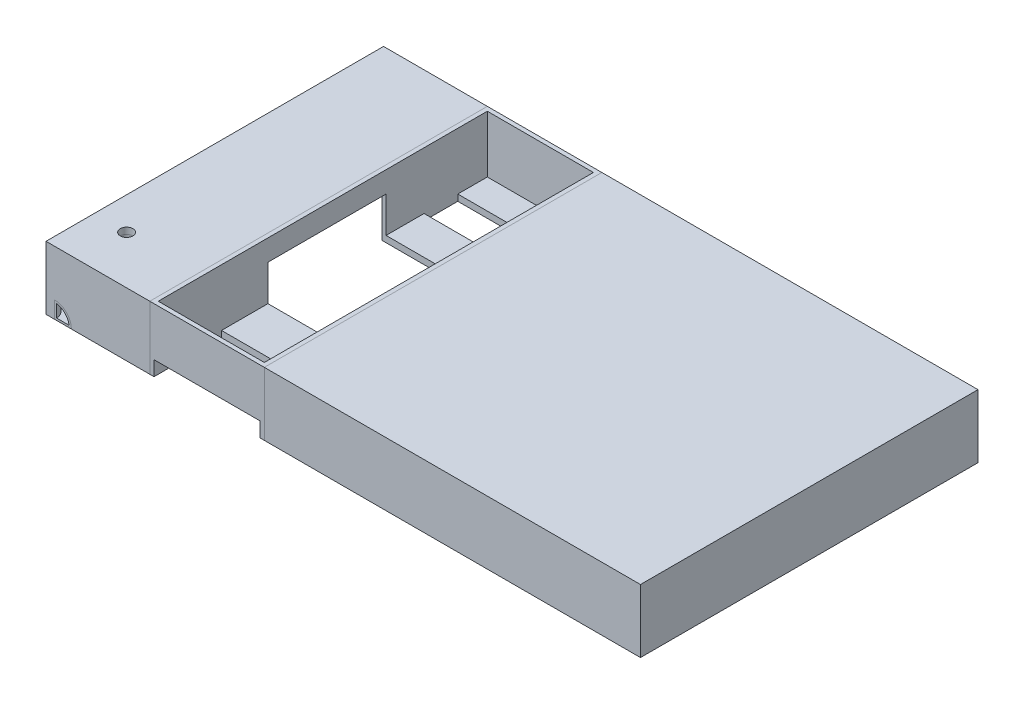
from build123d import *

# Parameters (mm, degrees)
SKETCH1_W                  = 140.9
SKETCH1_H                  = 80
BOSS_EXTRUDE1_DEPTH        = 15
SHELL3_T                   = -1.5
CUT_EXTRUDE2_DEPTH         = 1.5
SKETCH6_W                  = 13.65
SKETCH6_H                  = 7.3
CUT_EXTRUDE3_DEPTH         = 1.5
SKETCH9_W                  = 15.65
SKETCH9_H                  = 1
BOSS_EXTRUDE2_DEPTH        = 1.5
SKETCH11_R                 = 1.5
BOSS_EXTRUDE10_DEPTH       = 11
SKETCH11_3_R               = 1.5
CUT_EXTRUDE10_DEPTH        = 1.5
SHELL9_T                   = 1
CUT_REVOLVE4_ANGLE         = 90
REVOLVE3_ANGLE             = 90
SHELL14_T                  = -0.5
SKETCH47_W                 = 27.15
SKETCH47_H                 = 15
CUT_EXTRUDE15_DEPTH        = 109.636101274
SKETCH47_2_W               = 27.15
SKETCH47_2_H               = 15
BOSS_EXTRUDE12_DEPTH       = 80
SHELL15_T                  = -1
SHELL15_THICKNESS_2_FACE_W = 78
SHELL15_THICKNESS_2_FACE_H = 25.15
SHELL15_THICKNESS_2_DEPTH  = 0.5
SKETCH52_W                 = 25.15
SKETCH52_H                 = 3.5
CUT_EXTRUDE21_DEPTH        = 1
SKETCH54_W                 = 28
SKETCH54_H                 = 10
CUT_EXTRUDE22_DEPTH        = 1
SKETCH55_W                 = 25.15
SKETCH55_H                 = 15
SKETCH55_H_2               = 28
SKETCH55_H_3               = 8
CUT_EXTRUDE23_DEPTH        = 1.5


with BuildPart() as part:
    # Sketch1 → Boss-Extrude1 (new body)
    with BuildSketch(Plane(origin=(0, 0, 0), x_dir=(1, 0, 0), z_dir=(0, 1, 0))):
        Rectangle(SKETCH1_W, SKETCH1_H)
    extrude(amount=BOSS_EXTRUDE1_DEPTH)

    # Shell3
    shell3_openings = [part.faces().sort_by_distance(p)[0] for p in [
        (0, 0, 0),
    ]]
    offset(amount=SHELL3_T, openings=shell3_openings, kind=Kind.INTERSECTION)

    # Sketch4 → Cut-Extrude2 (cut)
    with BuildSketch(Plane.ZY.offset(70.45)):
        with BuildLine():
            Line((-34.38, 3.3), (-28.48, 3.3))
            ThreePointArc((-28.48, 3.3), (-26.78, 1.6), (-28.48, -0.1))
            Line((-28.48, -0.1), (-34.38, -0.1))
            ThreePointArc((-34.38, -0.1), (-36.08, 1.6), (-34.38, 3.3))
        make_face()
    extrude(amount=-CUT_EXTRUDE2_DEPTH, mode=Mode.SUBTRACT)

    # Sketch6 → Cut-Extrude3 (cut)
    with BuildSketch(Plane.ZY.offset(70.45)):
        with Locations((-17.575, 3.65)):
            Rectangle(SKETCH6_W, SKETCH6_H)
    extrude(amount=-CUT_EXTRUDE3_DEPTH, mode=Mode.SUBTRACT)

    # Sketch9 → Boss-Extrude2 (add)
    with BuildSketch(Plane.ZY.offset(70.45)):
        with Locations((-17.575, 0.5)):
            Rectangle(SKETCH9_W, SKETCH9_H)
    extrude(amount=BOSS_EXTRUDE2_DEPTH)

    # Sketch11 → Boss-Extrude10 (add)
    with BuildSketch(Plane(origin=(0, 15, 0), x_dir=(1, 0, 0), z_dir=(0, 1, 0))):
        with Locations(Location((-62.75, -28.6, 0), (0, 0, 270))):
            Circle(SKETCH11_R)
    extrude(amount=-BOSS_EXTRUDE10_DEPTH)

    # Sketch11_3 → Cut-Extrude10 (cut)
    with BuildSketch(Plane(origin=(0, 15, 0), x_dir=(1, 0, 0), z_dir=(0, 1, 0))):
        with Locations(Location((-62.75, -28.6, 0), (0, 0, 270))):
            Circle(SKETCH11_3_R)
    extrude(amount=-CUT_EXTRUDE10_DEPTH, mode=Mode.SUBTRACT)


with BuildPart() as cut_extrude10_piece_1:
    # of the separate pieces the step leaves, piece 1, a body of its own (cut_extrude10_pieces)
    add(part.part.solids().sort_by_distance((-70.45, 0, 40))[0])

    # Sketch33 → Cut-Revolve4 (revolve, cut)
    with BuildSketch(Plane.XY.offset(40)):
        with BuildLine():
            Line((-68.45, 4), (-68.45, 0))
            Line((-68.45, 0), (-64.45, 0))
            ThreePointArc((-64.45, 0), (-65.621572875, 2.828427125), (-68.45, 4))
        make_face()
    revolve(axis=Axis((-70.45, 15, 40), (0, 1, 0)), revolution_arc=CUT_REVOLVE4_ANGLE, mode=Mode.SUBTRACT)

    # Sketch47 → Cut-Extrude15 (cut, through all)
    with BuildSketch(Plane.XY.offset(40)):
        with Locations((-32.275, 7.5)):
            Rectangle(SKETCH47_W, SKETCH47_H)
    extrude(amount=-CUT_EXTRUDE15_DEPTH, mode=Mode.SUBTRACT)


with BuildPart() as cut_extrude10_piece_2:
    # of the separate pieces the step leaves, piece 2, a body of its own (cut_extrude10_pieces)
    add(part.part.solids().sort_by_distance((-62.75, 4, 30.1))[0])

    # Shell9
    shell9_openings = [cut_extrude10_piece_2.faces().sort_by_distance(p)[0] for p in [
        (-62.75, 4, 28.6),
        (-62.75, 13.5, 28.6),
    ]]
    offset(amount=SHELL9_T, openings=shell9_openings, kind=Kind.INTERSECTION)


with BuildPart() as body_3:
    # Sketch33_2 → Revolve3 (revolve)
    with BuildSketch(Plane.XY.offset(40)):
        with BuildLine():
            Line((-68.45, 4), (-68.45, 0))
            Line((-68.45, 0), (-64.45, 0))
            ThreePointArc((-64.45, 0), (-65.621572875, 2.828427125), (-68.45, 4))
        make_face()
    revolve(axis=Axis((-70.45, 15, 40), (0, 1, 0)), revolution_arc=REVOLVE3_ANGLE)

    # Shell14
    shell14_openings = [body_3.faces().sort_by_distance(p)[0] for p in [
        (-70.45, 1.697652726, 36.302347274),
        (-66.752347274, 1.697652726, 40),
    ]]
    offset(amount=SHELL14_T, openings=shell14_openings)


with BuildPart() as cut_extrude15_piece_1:
    # of the separate pieces the step leaves, piece 1, a body of its own (cut_extrude15_pieces)
    add(cut_extrude10_piece_1.part.solids().sort_by_distance((-18.7, 0, 40))[0])


with BuildPart() as cut_extrude15_piece_2:
    # of the separate pieces the step leaves, piece 2, a body of its own (cut_extrude15_pieces)
    add(cut_extrude10_piece_1.part.solids().sort_by_distance((-70.45, 0, 40))[0])


with BuildPart() as body_5:
    # Sketch47_2 → Boss-Extrude12 (new body)
    with BuildSketch(Plane.XY.offset(40)):
        with Locations((-32.275, 7.5)):
            Rectangle(SKETCH47_2_W, SKETCH47_2_H)
    extrude(amount=-BOSS_EXTRUDE12_DEPTH)

    # Shell15
    shell15_openings = [body_5.faces().sort_by_distance(p)[0] for p in [
        (-32.275, 15, 0),
    ]]
    offset(amount=SHELL15_T, openings=shell15_openings, kind=Kind.INTERSECTION)

    # Shell15 thickness 2 face (on inner face of the shell) → Shell15 thickness 2 (add)
    with BuildSketch(Plane(origin=(-32.275, 1, 0), x_dir=(0, 0, -1), z_dir=(0, -1, 0))):
        Rectangle(SHELL15_THICKNESS_2_FACE_W, SHELL15_THICKNESS_2_FACE_H)
    extrude(amount=-SHELL15_THICKNESS_2_DEPTH)

    # Sketch52 → Cut-Extrude21 (cut)
    with BuildSketch(Plane(origin=(0, 0, 39), x_dir=(-1, 0, 0), z_dir=(0, 0, -1))):
        with Locations((32.275, 1.75)):
            Rectangle(SKETCH52_W, SKETCH52_H)
    extrude(amount=-CUT_EXTRUDE21_DEPTH, mode=Mode.SUBTRACT)

    # Sketch54 → Cut-Extrude22 (cut)
    with BuildSketch(Plane(origin=(-44.85, 0, 0), x_dir=(0, 0, -1), z_dir=(1, 0, 0))):
        with Locations((1, 5)):
            Rectangle(SKETCH54_W, SKETCH54_H)
    extrude(amount=-CUT_EXTRUDE22_DEPTH, mode=Mode.SUBTRACT)

    # Sketch55 → Cut-Extrude23 (cut)
    with BuildSketch(Plane(origin=(0, 1.5, 0), x_dir=(1, 0, 0), z_dir=(0, 1, 0))):
        with Locations((-32.275, -31.5)):
            Rectangle(SKETCH55_W, SKETCH55_H)
        with Locations((-32.275, 1)):
            Rectangle(SKETCH55_W, SKETCH55_H_2)
        with Locations((-32.275, 28)):
            Rectangle(SKETCH55_W, SKETCH55_H_3)
    extrude(amount=-CUT_EXTRUDE23_DEPTH, mode=Mode.SUBTRACT)


solid = Compound([cut_extrude10_piece_2.part, body_3.part, cut_extrude15_piece_1.part, cut_extrude15_piece_2.part, body_5.part])
